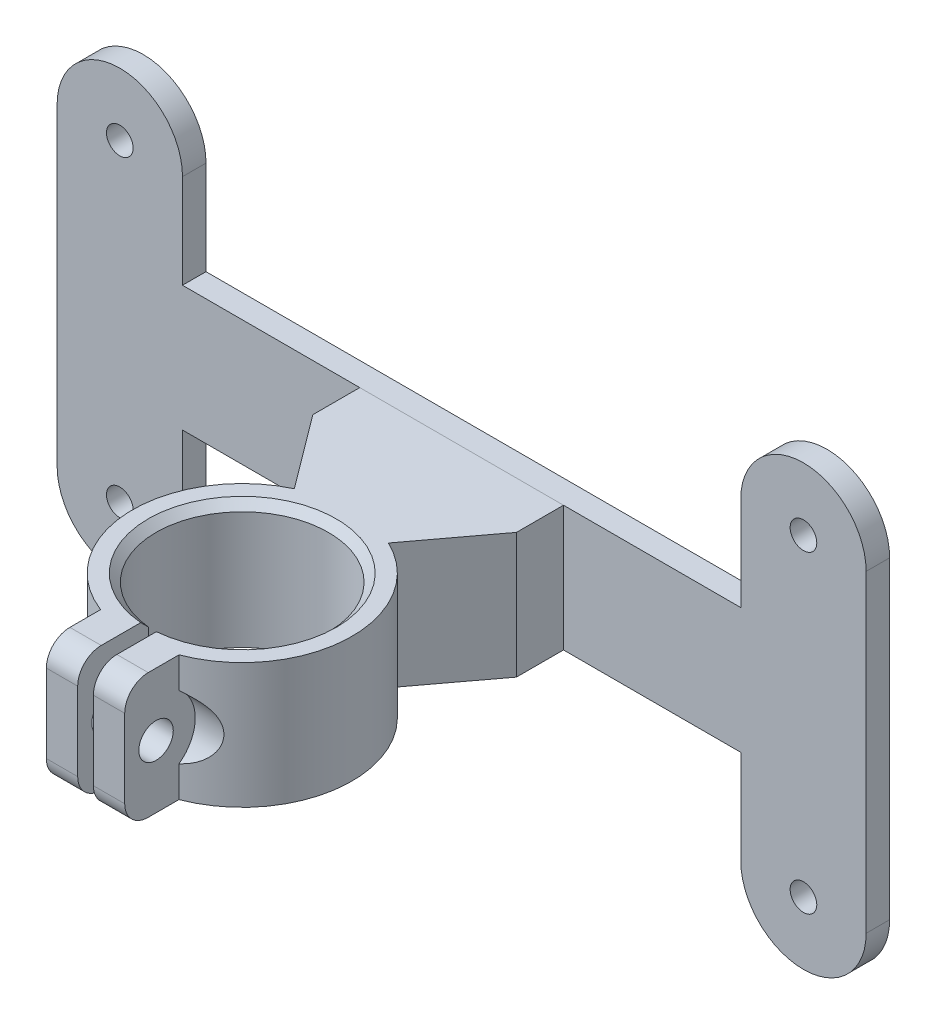
from build123d import *

# Parameters (mm, degrees)
SKETCH1_R               = 1.7
SKETCH1_W               = 71.25
SKETCH1_H               = 16
BOSS_EXTRUDE1_DEPTH     = 3
BOSS_EXTRUDE2_DEPTH     = 13
SKETCH5_R               = 11
BOSS_EXTRUDE3_DEPTH     = 16
BOSS_EXTRUDE4_DEPTH     = 16
SKETCH7_W               = 2
SKETCH7_H               = 12
CUT_EXTRUDE1_DEPTH      = 37
SKETCH8_R               = 2.2
CUT_EXTRUDE2_DEPTH      = 5
CUT_EXTRUDE2_DEPTH_BACK = 15
SKETCH9_R               = 5
CUT_EXTRUDE3_DEPTH      = 5
CUT_EXTRUDE4_DEPTH      = 13.5
FILLET1_R               = 3
CHAMFER1_SIZE           = 1


with BuildPart() as part:
    # Sketch1 → Boss-Extrude1 (new body)
    with BuildSketch(Plane.XY):
        with BuildLine():
            Line((-35.625, 8), (-35.625, 20))
            ThreePointArc((-35.625, 20), (-43.625, 28), (-51.625, 20))
            Line((-51.625, 20), (-51.625, 9e-09))
            ThreePointArc((-51.625, 9e-09), (-49.281854246, 5.656854253), (-43.625, 8))
            Line((-43.625, 8), (-35.625, 8))
        make_face()
        with Locations((-43.625, 20)):
            Circle(SKETCH1_R, mode=Mode.SUBTRACT)
        with BuildLine():
            Line((-35.625, -20), (-35.625, -8))
            Line((-35.625, -8), (-43.625, -8))
            ThreePointArc((-43.625, -8), (-49.281854253, -5.656854246), (-51.625, 9e-09))
            Line((-51.625, 9e-09), (-51.625, -20))
            ThreePointArc((-51.625, -20), (-43.625, -28), (-35.625, -20))
        make_face()
        with Locations((-43.625, -20)):
            Circle(SKETCH1_R, mode=Mode.SUBTRACT)
        Rectangle(SKETCH1_W, SKETCH1_H)
        with BuildLine():
            Line((-35.625, -8), (-35.625, 8))
            Line((-35.625, 8), (-43.625, 8))
            ThreePointArc((-43.625, 8), (-49.281854246, 5.656854253), (-51.625, 9e-09))
            ThreePointArc((-51.625, 9e-09), (-49.281854253, -5.656854246), (-43.625, -8))
            Line((-43.625, -8), (-35.625, -8))
        make_face()
        with BuildLine():
            Line((43.625, 8), (35.625, 8))
            Line((35.625, 8), (35.625, -8))
            Line((35.625, -8), (43.625, -8))
            ThreePointArc((43.625, -8), (49.281854249, -5.656854249), (51.625, 0))
            ThreePointArc((51.625, 0), (49.281854249, 5.656854249), (43.625, 8))
        make_face()
        with BuildLine():
            Line((35.625, 20), (35.625, 8))
            Line((35.625, 8), (43.625, 8))
            ThreePointArc((43.625, 8), (49.281854249, 5.656854249), (51.625, 0))
            Line((51.625, 0), (51.625, 20))
            ThreePointArc((51.625, 20), (43.625, 28), (35.625, 20))
        make_face()
        with Locations((43.625, 20)):
            Circle(SKETCH1_R, mode=Mode.SUBTRACT)
        with BuildLine():
            Line((43.625, -8), (35.625, -8))
            Line((35.625, -8), (35.625, -20))
            ThreePointArc((35.625, -20), (43.625, -28), (51.625, -20))
            Line((51.625, -20), (51.625, 0))
            ThreePointArc((51.625, 0), (49.281854249, -5.656854249), (43.625, -8))
        make_face()
        with Locations((43.625, -20)):
            Circle(SKETCH1_R, mode=Mode.SUBTRACT)
    extrude(amount=BOSS_EXTRUDE1_DEPTH)

    # Sketch2 → Boss-Extrude2 (add)
    with BuildSketch(Plane.XZ.offset(8)):
        Polygon((-10, 6), (10, 6), (7.5, 3), (-7.5, 3), align=None)
    extrude(amount=-BOSS_EXTRUDE2_DEPTH)


with BuildPart() as body_2:
    # Sketch5 → Boss-Extrude3 (new body)
    with BuildSketch(Plane(origin=(0, 8, 0), x_dir=(1, 0, 0), z_dir=(0, 1, 0))):
        with BuildLine():
            Line((-13, -3), (13, -3))
            Line((13, -3), (13, -9))
            Line((13, -9), (6, -18.350889359))
            ThreePointArc((6, -18.350889359), (0, -45), (-6, -18.350889359))
            Line((-6, -18.350889359), (-13, -9))
            Line((-13, -9), (-13, -3))
        make_face()
        with Locations((0, -31)):
            Circle(SKETCH5_R, mode=Mode.SUBTRACT)
    extrude(amount=-BOSS_EXTRUDE3_DEPTH)

    # Sketch6 → Boss-Extrude4 (add)
    with BuildSketch(Plane(origin=(0, 8, 0), x_dir=(1, 0, 0), z_dir=(0, 1, 0))):
        with BuildLine():
            ThreePointArc((5, -44.076696831), (0, -45), (-5, -44.076696831))
            Line((-5, -44.076696831), (-5, -51))
            Line((-5, -51), (5, -51))
            Line((5, -51), (5, -44.076696831))
        make_face()
    extrude(amount=-BOSS_EXTRUDE4_DEPTH)

    # Sketch7 → Cut-Extrude1 (cut, through all)
    with BuildSketch(Plane(origin=(0, 8, 0), x_dir=(1, 0, 0), z_dir=(0, 1, 0))):
        with Locations((0, -45)):
            Rectangle(SKETCH7_W, SKETCH7_H)
    extrude(amount=-CUT_EXTRUDE1_DEPTH, mode=Mode.SUBTRACT)

    # Sketch8 → Cut-Extrude2 (cut, two sides)
    with BuildSketch(Plane.ZY.offset(5)) as cut_extrude2_sk:
        with Locations((47, 0)):
            Circle(SKETCH8_R)
    extrude(amount=CUT_EXTRUDE2_DEPTH, mode=Mode.SUBTRACT)
    extrude(cut_extrude2_sk.sketch, amount=-CUT_EXTRUDE2_DEPTH_BACK, mode=Mode.SUBTRACT)

    # Sketch9 → Cut-Extrude3 (cut)
    with BuildSketch(Plane.ZY.offset(5)):
        with Locations((47, 0)):
            Circle(SKETCH9_R)
    cut_extrude3 = extrude(amount=CUT_EXTRUDE3_DEPTH, mode=Mode.SUBTRACT)

    # Mirror1: Cut-Extrude3 across plane
    add(cut_extrude3.mirror(Plane(origin=(0, 0, 0), x_dir=(0, 0, 1), z_dir=(1, 0, 0))), mode=Mode.SUBTRACT)

    # Sketch10 → Cut-Extrude4 (cut)
    with BuildSketch(Plane.XZ.offset(8)):
        Polygon((-7.653644256, 2.87196312), (7.653644256, 2.87196312), (10.427008323, 6.2), (-10.427008323, 6.2), align=None)
    extrude(amount=-CUT_EXTRUDE4_DEPTH, mode=Mode.SUBTRACT)

    # Fillet1
    fillet1_edges = [body_2.edges().sort_by_distance(p)[0] for p in [
        (-3, -8, 51),
        (-3, 8, 51),
        (3, 8, 51),
        (3, -8, 51),
    ]]
    fillet(fillet1_edges, radius=FILLET1_R)

    # Chamfer1
    chamfer1_edges = [body_2.edges().sort_by_distance(p)[0] for p in [
        (0, 8, 20),
    ]]
    chamfer(chamfer1_edges, length=CHAMFER1_SIZE)


solid = Compound([part.part, body_2.part])
